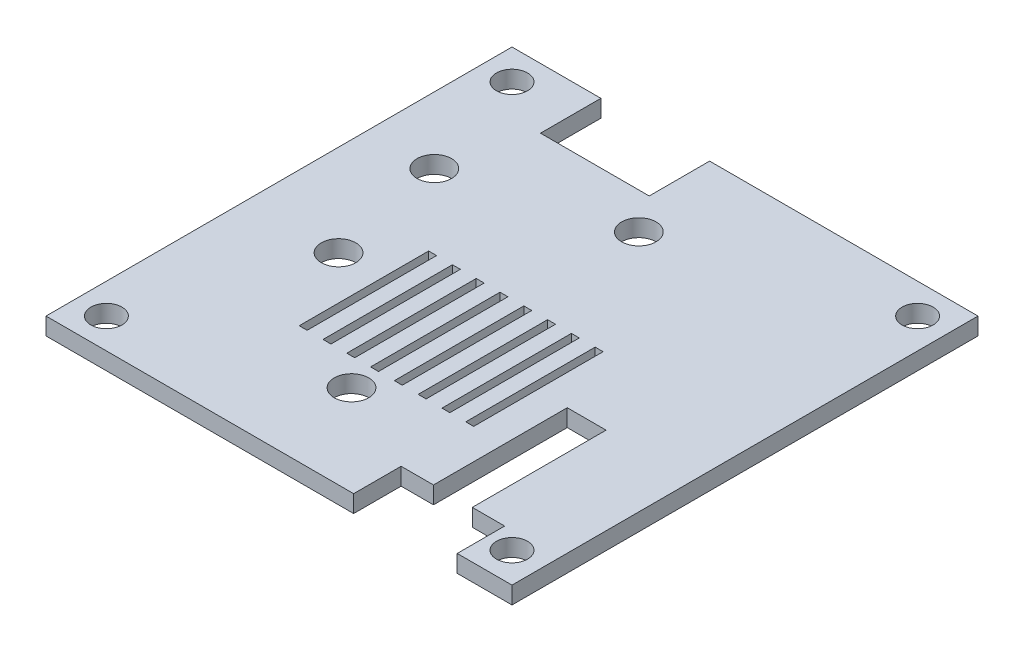
from build123d import *

# Parameters (mm, degrees)
SKETCH_3_R      = 2
SKETCH_3_W      = 0.91875
SKETCH_3_H      = 15
SKETCH_3_R_2    = 1.8
EXTRUDE_2_DEPTH = 2


with BuildPart() as part:
    # 草图3 → 凸台-拉伸2 (new body)
    with BuildSketch(Plane(origin=(0, 0, 0), x_dir=(1, 0, 0), z_dir=(0, 1, 0))):
        Polygon((16.9, -21.5), (20.65, -21.5), (20.65, -27), (27, -27), (27, 27), (-4.1, 27), (-4.1, 20), (-16.7, 20), (-16.7, 27), (-27, 27), (-27, -27), (8.65, -27), (8.65, -21.5), (12.4, -21.5), (12.4, -6), (16.9, -6), align=None)
        with Locations((-19.3, 10.3)):
            Circle(SKETCH_3_R, mode=Mode.SUBTRACT)
        with Locations((-2.1, -16.5)):
            Circle(SKETCH_3_R, mode=Mode.SUBTRACT)
        with Locations((-16.4, -3.7)):
            Circle(SKETCH_3_R, mode=Mode.SUBTRACT)
        with Locations((-10.896875, -5.8)):
            Rectangle(SKETCH_3_W, SKETCH_3_H, mode=Mode.SUBTRACT)
        with Locations((-8.140625, -5.8)):
            Rectangle(SKETCH_3_W, SKETCH_3_H, mode=Mode.SUBTRACT)
        with Locations((-5.384375, -5.8)):
            Rectangle(SKETCH_3_W, SKETCH_3_H, mode=Mode.SUBTRACT)
        with Locations((-2.628125, -5.8)):
            Rectangle(SKETCH_3_W, SKETCH_3_H, mode=Mode.SUBTRACT)
        with Locations((0.128125, -5.8)):
            Rectangle(SKETCH_3_W, SKETCH_3_H, mode=Mode.SUBTRACT)
        with Locations((2.884375, -5.8)):
            Rectangle(SKETCH_3_W, SKETCH_3_H, mode=Mode.SUBTRACT)
        with Locations((23.5, -23.5)):
            Circle(SKETCH_3_R_2, mode=Mode.SUBTRACT)
        with Locations((5.640625, -5.8)):
            Rectangle(SKETCH_3_W, SKETCH_3_H, mode=Mode.SUBTRACT)
        with Locations((8.396875, -5.8)):
            Rectangle(SKETCH_3_W, SKETCH_3_H, mode=Mode.SUBTRACT)
        with Locations((-1.1, 15.8)):
            Circle(SKETCH_3_R, mode=Mode.SUBTRACT)
        with Locations((23.5, 23.5)):
            Circle(SKETCH_3_R_2, mode=Mode.SUBTRACT)
        with Locations((-23.5, -23.5)):
            Circle(SKETCH_3_R_2, mode=Mode.SUBTRACT)
        with Locations((-23.5, 23.5)):
            Circle(SKETCH_3_R_2, mode=Mode.SUBTRACT)
    extrude(amount=EXTRUDE_2_DEPTH)


solid = part.part
